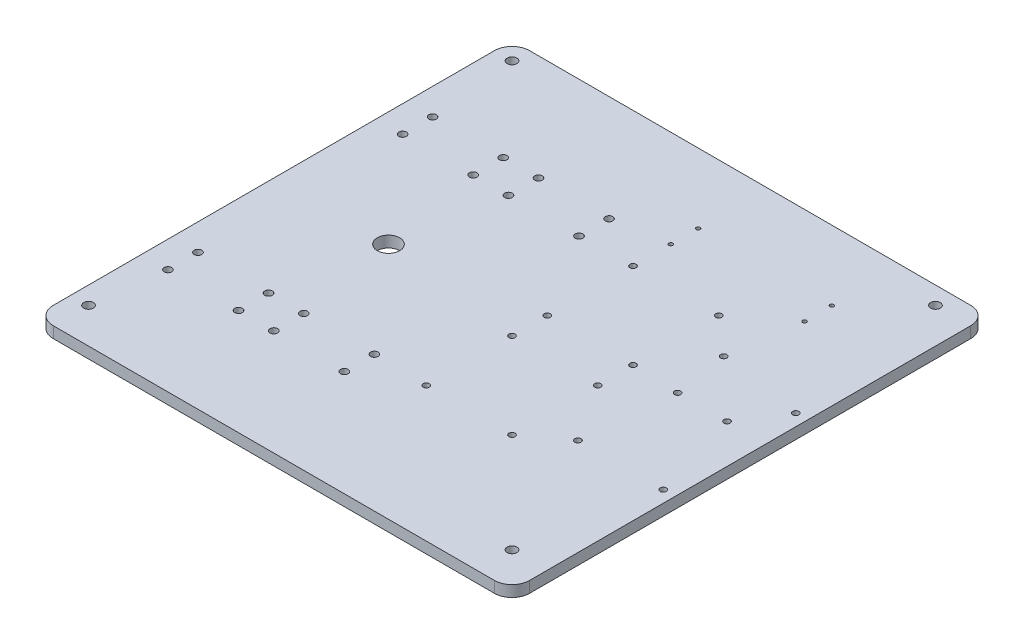
from build123d import *

# Parameters (mm, degrees)
SKETCH1_W               = 270
SKETCH1_H               = 270
BOSS_EXTRUDE1_DEPTH     = 6.35
SKETCH3_R               = 2.15
CUT_EXTRUDE1_DEPTH      = 7.35
MIRROR2_COPY_1_SKETCH_R = 2.15
MIRROR2_COPY_1_DEPTH    = 7.35
SKETCH4_R               = 6.35
CUT_EXTRUDE2_DEPTH      = 7.35
SKETCH6_R               = 1.75
CUT_EXTRUDE4_DEPTH      = 7.35
SKETCH7_R               = 1.1
CUT_EXTRUDE5_DEPTH      = 7.35
FILLET1_R               = 10
CUT_EXTRUDE6_REACH      = 8.35
SKETCH8_R               = 2.75


with BuildPart() as part:
    # Sketch1 → Boss-Extrude1 (new body)
    with BuildSketch(Plane(origin=(0, 0, 0), x_dir=(1, 0, 0), z_dir=(0, 1, 0))):
        with Locations((70, 0)):
            Rectangle(SKETCH1_W, SKETCH1_H)
    extrude(amount=BOSS_EXTRUDE1_DEPTH)

    # Sketch3 → Cut-Extrude1 (cut, through all)
    with BuildSketch(Plane(origin=(0, 6.35, 0), x_dir=(1, 0, 0), z_dir=(0, 1, 0))):
        with Locations((-50, -58)):
            Circle(SKETCH3_R)
        with Locations((-10, -58)):
            Circle(SKETCH3_R)
        with Locations((-50, -75)):
            Circle(SKETCH3_R)
        with Locations((-10, -75)):
            Circle(SKETCH3_R)
    cut_extrude1 = extrude(amount=-CUT_EXTRUDE1_DEPTH, mode=Mode.SUBTRACT)

    # Mirror1: Cut-Extrude1 across plane
    add(cut_extrude1.mirror(Plane(origin=(0, 0, 0), x_dir=(0, 0, 1), z_dir=(1, 0, 0))), mode=Mode.SUBTRACT)

    # Mirror2: Cut-Extrude1 across plane
    add(cut_extrude1.mirror(Plane.XY), mode=Mode.SUBTRACT)

    # Mirror2 copy 1 sketch → Mirror2 copy 1 (cut, through all)
    with BuildSketch(Plane(origin=(0, 6.35, 0), x_dir=(-1, 0, 0), z_dir=(0, 1, 0))):
        with Locations((-50, -58)):
            Circle(MIRROR2_COPY_1_SKETCH_R)
        with Locations((-10, -58)):
            Circle(MIRROR2_COPY_1_SKETCH_R)
        with Locations((-50, -75)):
            Circle(MIRROR2_COPY_1_SKETCH_R)
        with Locations((-10, -75)):
            Circle(MIRROR2_COPY_1_SKETCH_R)
    extrude(amount=-MIRROR2_COPY_1_DEPTH, mode=Mode.SUBTRACT)

    # Sketch4 → Cut-Extrude2 (cut, through all)
    with BuildSketch(Plane(origin=(0, 6.35, 0), x_dir=(1, 0, 0), z_dir=(0, 1, 0))):
        Circle(SKETCH4_R)
    extrude(amount=-CUT_EXTRUDE2_DEPTH, mode=Mode.SUBTRACT)

    # Sketch6 → Cut-Extrude4 (cut, through all)
    with BuildSketch(Plane.XZ):
        with Locations((80, -58.6)):
            Circle(SKETCH6_R)
        with Locations((80, -10)):
            Circle(SKETCH6_R)
        with Locations((128.6, -58.6)):
            Circle(SKETCH6_R)
        with Locations((128.6, -10)):
            Circle(SKETCH6_R)
        with Locations((80, 10)):
            Circle(SKETCH6_R)
        with Locations((80, 58.6)):
            Circle(SKETCH6_R)
        with Locations((128.6, 58.6)):
            Circle(SKETCH6_R)
        with Locations((128.6, 10)):
            Circle(SKETCH6_R)
        with Locations((198.3362, 42.6262)):
            Circle(SKETCH6_R)
        with Locations((150, 42.6262)):
            Circle(SKETCH6_R)
        with Locations((150, -40)):
            Circle(SKETCH6_R)
        with Locations((154.878492766, -8.9993)):
            Circle(SKETCH6_R)
        with Locations((198.3362, -32.507)):
            Circle(SKETCH6_R)
        with Locations((182.894692766, -8.9993)):
            Circle(SKETCH6_R)
    extrude(amount=-CUT_EXTRUDE4_DEPTH, mode=Mode.SUBTRACT)

    # Sketch7 → Cut-Extrude5 (cut, through all)
    with BuildSketch(Plane.XZ):
        with Locations((155.8, -95.5)):
            Circle(SKETCH7_R)
        with Locations((80, -95.5)):
            Circle(SKETCH7_R)
        with Locations((80, -80)):
            Circle(SKETCH7_R)
        with Locations((155.8, -80)):
            Circle(SKETCH7_R)
    extrude(amount=-CUT_EXTRUDE5_DEPTH, mode=Mode.SUBTRACT)

    # Fillet1
    fillet1_edges = [part.edges().sort_by_distance(p)[0] for p in [
        (-65, 3.175, -135),
        (205, 3.175, -135),
        (205, 3.175, 135),
        (-65, 3.175, 135),
    ]]
    fillet(fillet1_edges, radius=FILLET1_R)

    # Sketch8 → Cut-Extrude6 (cut, up to next)
    with BuildSketch(Plane(origin=(0, 6.35, 0), x_dir=(1, 0, 0), z_dir=(0, 1, 0)), mode=Mode.PRIVATE) as cut_extrude6_sk1:
        with Locations((-55, 125)):
            Circle(SKETCH8_R)
    cut_extrude6_tool1 = extrude(cut_extrude6_sk1.sketch, amount=-CUT_EXTRUDE6_REACH, mode=Mode.PRIVATE) & part.part
    add(cut_extrude6_tool1.solids().sort_by_distance((-55, 6.35, -125))[0], mode=Mode.SUBTRACT)
    # Sketch8 → Cut-Extrude6 (cut, up to next)
    with BuildSketch(Plane(origin=(0, 6.35, 0), x_dir=(1, 0, 0), z_dir=(0, 1, 0)), mode=Mode.PRIVATE) as cut_extrude6_sk2:
        with Locations((185, 125)):
            Circle(SKETCH8_R)
    cut_extrude6_tool2 = extrude(cut_extrude6_sk2.sketch, amount=-CUT_EXTRUDE6_REACH, mode=Mode.PRIVATE) & part.part
    add(cut_extrude6_tool2.solids().sort_by_distance((185, 6.35, -125))[0], mode=Mode.SUBTRACT)
    # Sketch8 → Cut-Extrude6 (cut, up to next)
    with BuildSketch(Plane(origin=(0, 6.35, 0), x_dir=(1, 0, 0), z_dir=(0, 1, 0)), mode=Mode.PRIVATE) as cut_extrude6_sk3:
        with Locations((-55, -115)):
            Circle(SKETCH8_R)
    cut_extrude6_tool3 = extrude(cut_extrude6_sk3.sketch, amount=-CUT_EXTRUDE6_REACH, mode=Mode.PRIVATE) & part.part
    add(cut_extrude6_tool3.solids().sort_by_distance((-55, 6.35, 115))[0], mode=Mode.SUBTRACT)
    # Sketch8 → Cut-Extrude6 (cut, up to next)
    with BuildSketch(Plane(origin=(0, 6.35, 0), x_dir=(1, 0, 0), z_dir=(0, 1, 0)), mode=Mode.PRIVATE) as cut_extrude6_sk4:
        with Locations((185, -115)):
            Circle(SKETCH8_R)
    cut_extrude6_tool4 = extrude(cut_extrude6_sk4.sketch, amount=-CUT_EXTRUDE6_REACH, mode=Mode.PRIVATE) & part.part
    add(cut_extrude6_tool4.solids().sort_by_distance((185, 6.35, 115))[0], mode=Mode.SUBTRACT)


solid = part.part
